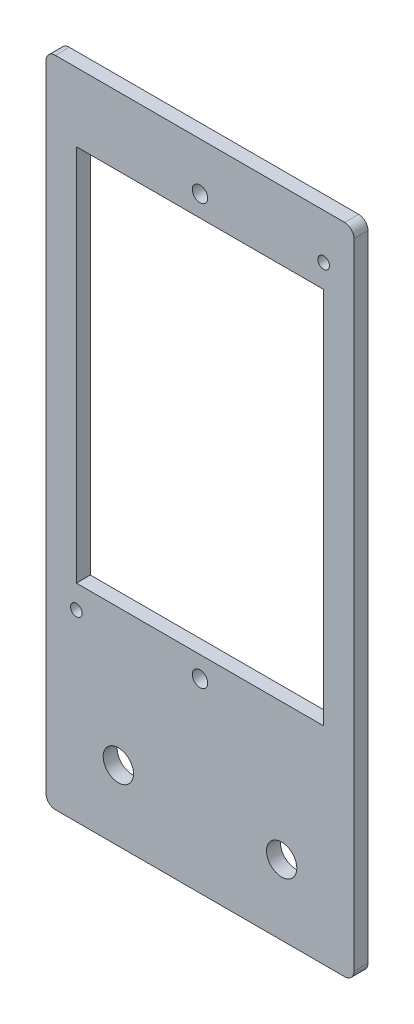
from build123d import *

# Parameters (mm, degrees)
SKETCH1_W             = 66
SKETCH1_H             = 140
SKETCH1_R             = 3.25
SKETCH1_W_2           = 53
SKETCH1_H_2           = 81
BOSS_EXTRUDE1_DEPTH   = 3
FILLET1_R             = 2
M4X0_7_TAPPED_HOLE1_D = 3.3
M3X0_5_TAPPED_HOLE1_D = 2.5


with BuildPart() as part:
    # Sketch1 → Boss-Extrude1 (new body)
    with BuildSketch(Plane.XY):
        with Locations((22.144812637, -44.667286245)):
            Rectangle(SKETCH1_W, SKETCH1_H)
        with Locations((4.644812637, -99.667286245)):
            Circle(SKETCH1_R, mode=Mode.SUBTRACT)
        with Locations((39.644812637, -99.667286245)):
            Circle(SKETCH1_R, mode=Mode.SUBTRACT)
        with Locations((22.144812637, -29.867286245)):
            Rectangle(SKETCH1_W_2, SKETCH1_H_2, mode=Mode.SUBTRACT)
    extrude(amount=BOSS_EXTRUDE1_DEPTH)

    # Fillet1
    fillet1_edges = [part.edges().sort_by_distance(p)[0] for p in [
        (-10.855187363, 25.332713755, 1.5),
        (55.144812637, 25.332713755, 1.5),
        (55.144812637, -114.667286245, 1.5),
        (-10.855187363, -114.667286245, 1.5),
    ]]
    fillet(fillet1_edges, radius=FILLET1_R)

    # M4x0.7 Tapped Hole1 (through all)
    with Locations(Plane.XY.offset(3)):
        with Locations((22.144812637, 15.132713755), (22.144812637, -74.867286245)):
            Hole(M4X0_7_TAPPED_HOLE1_D / 2)

    # M3x0.5 Tapped Hole1 (through all)
    with Locations(Plane.XY.offset(3)):
        with Locations((48.644812637, 15.632713755), (-4.355187363, -75.367286245)):
            Hole(M3X0_5_TAPPED_HOLE1_D / 2)


solid = part.part
